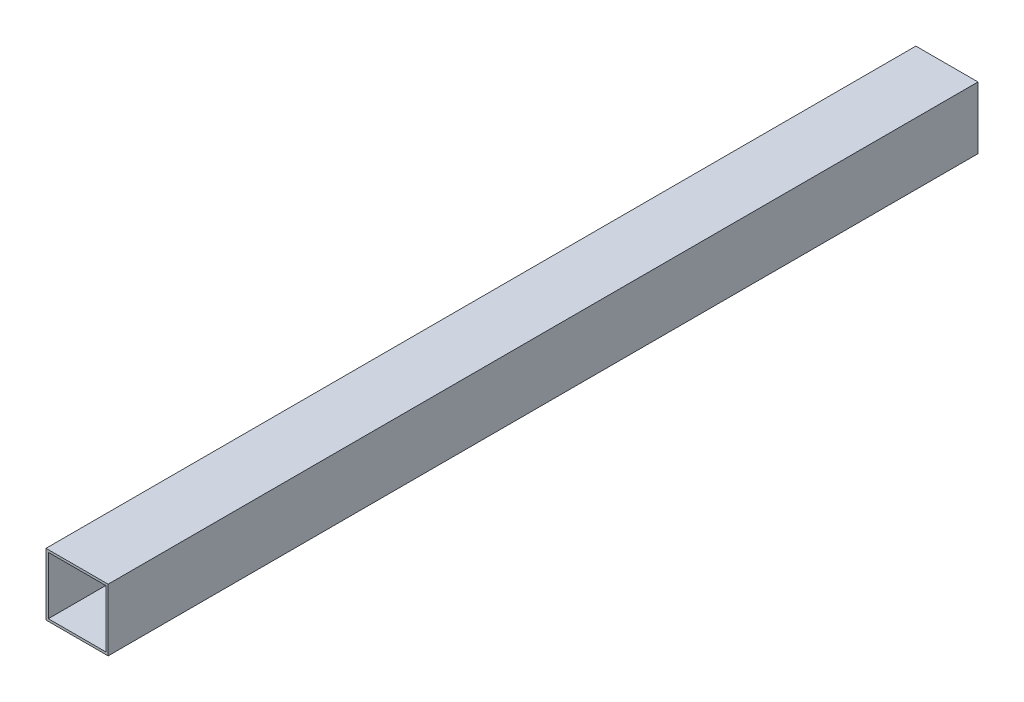
from build123d import *

# Parameters (mm, degrees)
ESQUISSE1_W        = 40
ESQUISSE1_H        = 40
ESQUISSE1_W_2      = 37
ESQUISSE1_H_2      = 37
BOSS_EXTRU_1_DEPTH = 560


with BuildPart() as part:
    # Esquisse1 → Boss.-Extru.1 (new body)
    with BuildSketch(Plane.XY):
        Rectangle(ESQUISSE1_W, ESQUISSE1_H)
        Rectangle(ESQUISSE1_W_2, ESQUISSE1_H_2, mode=Mode.SUBTRACT)
    extrude(amount=BOSS_EXTRU_1_DEPTH)


solid = part.part
